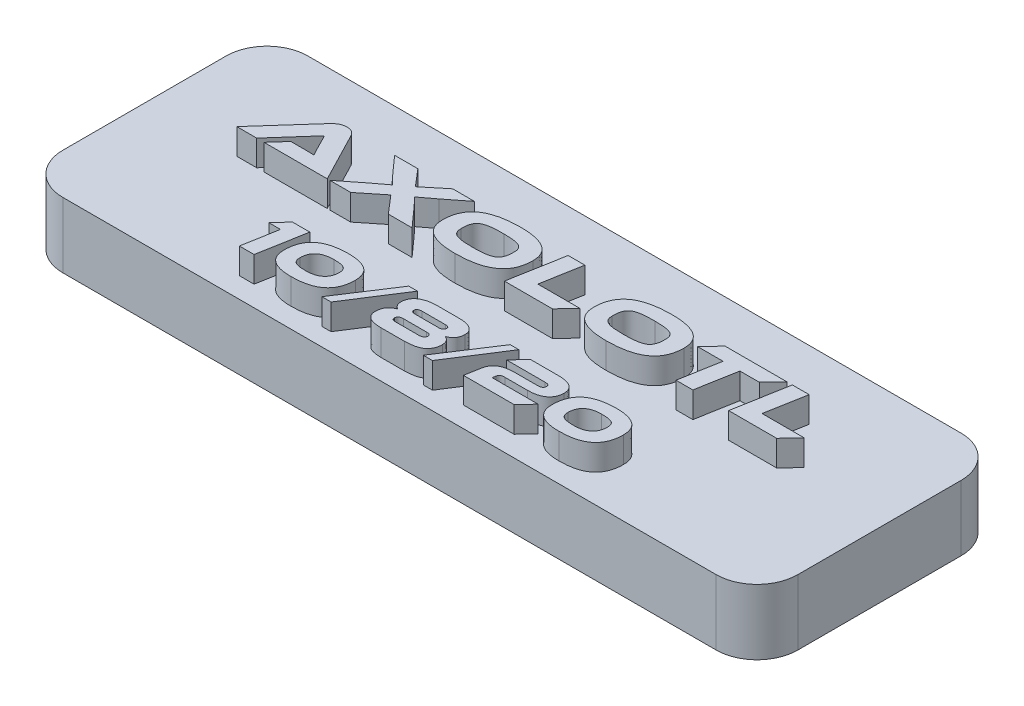
from build123d import *

# Parameters (mm, degrees)
SKETCH1_W           = 57.15
SKETCH1_H           = 19.05
BOSS_EXTRUDE1_DEPTH = 5.08
FILLET1_R           = 3.175
BOSS_EXTRUDE2_DEPTH = 2
SKETCH4_R           = 0.9
CUT_EXTRUDE1_DEPTH  = 4


with BuildPart() as part:
    # Sketch1 → Boss-Extrude1 (new body)
    with BuildSketch(Plane(origin=(0, 0, 0), x_dir=(1, 0, 0), z_dir=(0, 1, 0))):
        Rectangle(SKETCH1_W, SKETCH1_H)
    extrude(amount=BOSS_EXTRUDE1_DEPTH)

    # Fillet1
    fillet1_edges = [part.edges().sort_by_distance(p)[0] for p in [
        (-28.575, 2.54, -9.525),
        (-28.575, 2.54, 9.525),
        (28.575, 2.54, 9.525),
        (28.575, 2.54, -9.525),
    ]]
    fillet(fillet1_edges, radius=FILLET1_R)

    # Sketch3 → Boss-Extrude2 (add)
    with BuildSketch(Plane(origin=(0, 5.08, 0), x_dir=(1, 0, 0), z_dir=(0, 1, 0))):
        Polygon((18.335777087, 1.105536066), (18.8918259, 4.208766837), (17.59016618, 4.208766837), (16.838236535, 0.006075914), (20.572609811, 0.006075914), (21.615201335, 1.105536066), align=None)
        Polygon((12.363724781, 4.206347541), (11.314814521, 3.106887389), (13.298897784, 3.106887389), (12.749167708, 0.003655726), (14.057146165, 0.003655726), (14.613194977, 3.106887389), (16.117054266, 3.106887389), (17.165964526, 4.206347541), align=None)
        with BuildLine():
            add(Edge.make_bspline(
                [(8.150404133, 4.264853435), (8.077331419, 4.264150041), (7.933827308, 4.262768679), (7.722365677, 4.255304453), (7.518089939, 4.243828802), (7.320895791, 4.226275073), (7.130668478, 4.204448808), (6.947363902, 4.178135377), (6.771067152, 4.146346882), (6.601929756, 4.108703546), (6.439953656, 4.066841285), (6.285091092, 4.020018599), (6.136881333, 3.969271115), (5.995622238, 3.912462076), (5.861728018, 3.850145336), (5.733958554, 3.784672178), (5.61390929, 3.713307743), (5.501420481, 3.636054084), (5.394894648, 3.555015487), (5.296173928, 3.467997248), (5.204320413, 3.375795294), (5.118249102, 3.27972572), (5.040508005, 3.176938462), (4.967822763, 3.070861845), (4.904381991, 2.958180712), (4.844853282, 2.842029764), (4.794160472, 2.71956376), (4.750442622, 2.592115874), (4.712505364, 2.460138961), (4.682839934, 2.322911611), (4.658964556, 2.180763117), (4.641635021, 2.033740252), (4.631310583, 1.881481624), (4.630569657, 1.778351657), (4.630192995, 1.725923865)],
                knots=[0, 0, 0, 0, 0.00021922, 0.000430517, 0.000634719, 0.000832939, 0.001024345, 0.001209088, 0.001388397, 0.001561619, 0.0017288, 0.001890173, 0.002046865, 0.002198625, 0.002346687, 0.00248979, 0.002629165, 0.002765325, 0.002898982, 0.003030471, 0.003159752, 0.003289265, 0.003417071, 0.003546125, 0.003674706, 0.003804712, 0.003937476, 0.004071906, 0.004208776, 0.004349179, 0.004492852, 0.004641052, 0.004793135, 0.004950393, 0.004950393, 0.004950393, 0.004950393], degree=3))
            add(Edge.make_bspline(
                [(4.630192995, 1.725923865), (4.632121436, 1.652651179), (4.635862655, 1.510500548), (4.669901525, 1.304743113), (4.723090378, 1.113533359), (4.798787304, 0.936607339), (4.896339962, 0.774301847), (5.016174769, 0.627005612), (5.158132033, 0.495143384), (5.321021618, 0.377875494), (5.505459788, 0.275513814), (5.710884064, 0.187096535), (5.937068575, 0.111278664), (6.184896364, 0.05083109), (6.453342007, 0.003624777), (6.743027316, -0.029580863), (7.05393382, -0.049844784), (7.268410788, -0.051940053), (7.379055845, -0.053020966)],
                knots=[0, 0, 0, 0, 0.000219671, 0.000426167, 0.000623813, 0.000813827, 0.001001645, 0.001190103, 0.001381548, 0.00158123, 0.001790776, 0.002013083, 0.002251287, 0.002505594, 0.002777627, 0.003068474, 0.003379936, 0.003711836, 0.003711836, 0.003711836, 0.003711836], degree=3))
            add(Edge.make_bspline(
                [(7.379055845, -0.053020966), (7.451890511, -0.052455169), (7.595158518, -0.051342229), (7.806679132, -0.043724787), (8.010969019, -0.032438481), (8.208136511, -0.014624257), (8.398458377, 0.006825126), (8.581630129, 0.034388638), (8.757965362, 0.066140884), (8.926831283, 0.103671999), (9.089012016, 0.145843098), (9.244523494, 0.191939017), (9.392566548, 0.24436261), (9.533842253, 0.30061376), (9.667425433, 0.363320067), (9.79483723, 0.429548791), (9.914587653, 0.501958418), (10.027365803, 0.579052293), (10.133795921, 0.660209293), (10.232901001, 0.747143393), (10.324109817, 0.84029394), (10.410537302, 0.93631177), (10.488233002, 1.03914999), (10.560890265, 1.145233071), (10.624622924, 1.258074334), (10.683644253, 1.374784654), (10.7346216, 1.497412041), (10.778293943, 1.624884051), (10.816229151, 1.756856749), (10.846015196, 1.894369804), (10.86968361, 2.036857562), (10.887125791, 2.184166254), (10.897429012, 2.336428379), (10.898172865, 2.439557863), (10.898551014, 2.491985411)],
                knots=[0, 0, 0, 0, 0.0002185, 0.000429796, 0.000634912, 0.000832221, 0.001023627, 0.001209407, 0.001387817, 0.001561039, 0.001728219, 0.001890468, 0.002047461, 0.002199222, 0.002346454, 0.00248998, 0.002629824, 0.002765984, 0.002899642, 0.003031131, 0.00316106, 0.003290573, 0.003418378, 0.003547433, 0.003676014, 0.003806837, 0.003939601, 0.004074031, 0.004210901, 0.004351303, 0.004495879, 0.004644079, 0.004796161, 0.00495342, 0.00495342, 0.00495342, 0.00495342], degree=3))
            add(Edge.make_bspline(
                [(10.898551014, 2.491985411), (10.896470083, 2.564930001), (10.892417642, 2.706983534), (10.860286286, 2.912703512), (10.806289001, 3.104122883), (10.730299981, 3.280748696), (10.632346519, 3.44245971), (10.513207523, 3.589369287), (10.371798288, 3.721034434), (10.208286355, 3.837071522), (10.024253575, 3.940135668), (9.818210998, 4.0266221), (9.592344192, 4.102333874), (9.344326207, 4.161421518), (9.075707698, 4.208718585), (8.78575134, 4.242297194), (8.474770739, 4.261022072), (8.260326341, 4.263336881), (8.150404133, 4.264853435)],
                knots=[0, 0, 0, 0, 0.000218758, 0.000426013, 0.00062278, 0.000813995, 0.001001031, 0.001188203, 0.001379648, 0.001578795, 0.001788342, 0.002011126, 0.002248172, 0.002502261, 0.002775194, 0.003066041, 0.003377445, 0.003709345, 0.003709345, 0.003709345, 0.003709345], degree=3))
        make_face()
        with BuildLine():
            add(Edge.make_bspline(
                [(7.569080374, 1.047030173), (7.500559737, 1.04660261), (7.368640483, 1.045779446), (7.17778066, 1.049733712), (7.00161625, 1.061186797), (6.839512598, 1.075736974), (6.691844576, 1.097737934), (6.558517858, 1.125013299), (6.438678126, 1.156348623), (6.332812518, 1.194530349), (6.23896382, 1.240026498), (6.159068437, 1.297252332), (6.090462452, 1.363776891), (6.036559465, 1.441900597), (5.993689516, 1.529303822), (5.963864806, 1.627061382), (5.9462797, 1.735031597), (5.945271135, 1.81026116), (5.944747295, 1.849334734)],
                knots=[0, 0, 0, 0, 0.000205565, 0.000395764, 0.000572537, 0.000735087, 0.000883892, 0.001020147, 0.001143219, 0.001255139, 0.001357344, 0.001455005, 0.001548736, 0.001642574, 0.001738242, 0.001839729, 0.001948086, 0.002065187, 0.002065187, 0.002065187, 0.002065187], degree=3))
            add(Edge.make_bspline(
                [(5.944747295, 1.849334734), (5.943098774, 1.911811071), (5.939942925, 2.031412847), (5.951840709, 2.203375738), (5.976801723, 2.359667266), (6.015650402, 2.50079582), (6.068915694, 2.626166729), (6.134480308, 2.737052728), (6.216292456, 2.83042282), (6.295498537, 2.895436203), (6.366149285, 2.940784123), (6.426646367, 2.971515459), (6.493736891, 2.999666566), (6.567001749, 3.026084681), (6.646519384, 3.05083148), (6.732576181, 3.072755525), (6.825516283, 3.09131218), (6.924608683, 3.110411596), (7.030942267, 3.124111193), (7.143324465, 3.137374608), (7.262575478, 3.147018552), (7.388136832, 3.155167115), (7.520386226, 3.161792983), (7.659070377, 3.165320712), (7.804444012, 3.166041701), (7.903476417, 3.165221911), (7.954059082, 3.164803188)],
                knots=[0, 0, 0, 0, 0.000187411, 0.00035877, 0.00051627, 0.000661555, 0.000796714, 0.00092386, 0.001046319, 0.001167112, 0.001230003, 0.001297872, 0.001370374, 0.001448163, 0.001531436, 0.001620123, 0.001714428, 0.001815734, 0.00192278, 0.002035947, 0.002155212, 0.002281633, 0.002413427, 0.002552426, 0.00269778, 0.002849532, 0.002849532, 0.002849532, 0.002849532], degree=3))
            add(Edge.make_bspline(
                [(7.954059082, 3.164803188), (8.022924332, 3.165086646), (8.156102179, 3.165634822), (8.348524647, 3.161832074), (8.526217236, 3.150341942), (8.6895122, 3.135653139), (8.838161527, 3.114010286), (8.972295861, 3.086275793), (9.092329867, 3.055550786), (9.197949994, 3.01670025), (9.291498522, 2.971781209), (9.370742945, 2.913989507), (9.439068997, 2.847457656), (9.494266406, 2.770130915), (9.535912659, 2.682069422), (9.564669472, 2.584313015), (9.582527367, 2.476491904), (9.583494431, 2.401253582), (9.583996715, 2.362175459)],
                knots=[0, 0, 0, 0, 0.000206599, 0.00039954, 0.000577225, 0.000740685, 0.000891298, 0.001027553, 0.001151508, 0.001262569, 0.001364775, 0.001461693, 0.001555424, 0.00164979, 0.00174506, 0.001846279, 0.001954636, 0.002071737, 0.002071737, 0.002071737, 0.002071737], degree=3))
            add(Edge.make_bspline(
                [(9.583996715, 2.362175459), (9.585619089, 2.300007823), (9.588724223, 2.181022384), (9.577152523, 2.009565903), (9.550925729, 1.85401663), (9.511992566, 1.713235889), (9.459097938, 1.587793863), (9.392329774, 1.477427264), (9.310300781, 1.383606431), (9.230834209, 1.317707612), (9.159095801, 1.272767382), (9.098250778, 1.241979786), (9.031581199, 1.212524455), (8.957796539, 1.186264377), (8.877930547, 1.161664348), (8.79118721, 1.139884782), (8.698270511, 1.119635522), (8.598433299, 1.102726509), (8.492431364, 1.086938186), (8.379614117, 1.074209563), (8.260377611, 1.064550242), (8.13451608, 1.056272217), (8.002261892, 1.049750773), (7.863274865, 1.046182113), (7.717900831, 1.045470465), (7.618868482, 1.046288949), (7.569080374, 1.047030173)],
                knots=[0, 0, 0, 0, 0.000186496, 0.000356944, 0.000514595, 0.000659, 0.000794159, 0.000921781, 0.00104424, 0.00116632, 0.001229983, 0.001297853, 0.001370716, 0.001448505, 0.001532652, 0.001621339, 0.001716727, 0.001817873, 0.001925047, 0.002038214, 0.00215839, 0.002283899, 0.002416606, 0.002555606, 0.002700959, 0.002852711, 0.002852711, 0.002852711, 0.002852711], degree=3))
        make_face(mode=Mode.SUBTRACT)
        Polygon((0.901020759, 1.105536066), (1.457069572, 4.208766837), (0.155409851, 4.208766837), (-0.596519793, 0.006075914), (3.137853483, 0.006075914), (4.180445006, 1.105536066), align=None)
        with BuildLine():
            add(Edge.make_bspline(
                [(-3.609280505, 4.264853435), (-3.682353219, 4.264150041), (-3.825857329, 4.262768679), (-4.037318961, 4.255304453), (-4.241594699, 4.243828802), (-4.438788847, 4.226275073), (-4.62901616, 4.204448808), (-4.812320736, 4.178135377), (-4.988617486, 4.146346882), (-5.157754882, 4.108703546), (-5.319730982, 4.066841285), (-5.474593546, 4.020018599), (-5.622803305, 3.969271115), (-5.7640624, 3.912462076), (-5.897956619, 3.850145336), (-6.025726084, 3.784672178), (-6.145775348, 3.713307743), (-6.258264157, 3.636054084), (-6.36478999, 3.555015487), (-6.463510709, 3.467997248), (-6.555364225, 3.375795294), (-6.641435535, 3.27972572), (-6.719176633, 3.176938462), (-6.791861874, 3.070861845), (-6.855302646, 2.958180712), (-6.914831356, 2.842029764), (-6.965524166, 2.71956376), (-7.009242016, 2.592115874), (-7.047179274, 2.460138961), (-7.076844704, 2.322911611), (-7.100720082, 2.180763117), (-7.118049617, 2.033740252), (-7.128374055, 1.881481624), (-7.129114981, 1.778351657), (-7.129491643, 1.725923865)],
                knots=[0, 0, 0, 0, 0.00021922, 0.000430517, 0.000634719, 0.000832939, 0.001024345, 0.001209088, 0.001388397, 0.001561619, 0.0017288, 0.001890173, 0.002046865, 0.002198625, 0.002346687, 0.00248979, 0.002629165, 0.002765325, 0.002898982, 0.003030471, 0.003159752, 0.003289265, 0.003417071, 0.003546125, 0.003674706, 0.003804712, 0.003937476, 0.004071906, 0.004208776, 0.004349179, 0.004492852, 0.004641052, 0.004793135, 0.004950393, 0.004950393, 0.004950393, 0.004950393], degree=3))
            add(Edge.make_bspline(
                [(-7.129491643, 1.725923865), (-7.127563201, 1.652651179), (-7.123821983, 1.510500548), (-7.089783113, 1.304743113), (-7.036594259, 1.113533359), (-6.960897334, 0.936607339), (-6.863344676, 0.774301847), (-6.743509869, 0.627005612), (-6.601552605, 0.495143384), (-6.43866302, 0.377875494), (-6.25422485, 0.275513814), (-6.048800574, 0.187096535), (-5.822616063, 0.111278664), (-5.574788274, 0.05083109), (-5.306342631, 0.003624777), (-5.016657321, -0.029580863), (-4.705750818, -0.049844784), (-4.49127385, -0.051940053), (-4.380628792, -0.053020966)],
                knots=[0, 0, 0, 0, 0.000219671, 0.000426167, 0.000623813, 0.000813827, 0.001001645, 0.001190103, 0.001381548, 0.00158123, 0.001790776, 0.002013083, 0.002251287, 0.002505594, 0.002777627, 0.003068474, 0.003379936, 0.003711836, 0.003711836, 0.003711836, 0.003711836], degree=3))
            add(Edge.make_bspline(
                [(-4.380628792, -0.053020966), (-4.307794126, -0.052455169), (-4.16452612, -0.051342229), (-3.953005506, -0.043724787), (-3.748715619, -0.032438481), (-3.551548127, -0.014624257), (-3.361226261, 0.006825126), (-3.178054509, 0.034388638), (-3.001719275, 0.066140884), (-2.832853354, 0.103671999), (-2.670672622, 0.145843098), (-2.515161144, 0.191939017), (-2.367118089, 0.24436261), (-2.225842384, 0.30061376), (-2.092259205, 0.363320067), (-1.964847408, 0.429548791), (-1.845096985, 0.501958418), (-1.732318834, 0.579052293), (-1.625888717, 0.660209293), (-1.526783636, 0.747143393), (-1.435574821, 0.84029394), (-1.349147336, 0.93631177), (-1.271451635, 1.03914999), (-1.198794373, 1.145233071), (-1.135061714, 1.258074334), (-1.076040385, 1.374784654), (-1.025063038, 1.497412041), (-0.981390695, 1.624884051), (-0.943455487, 1.756856749), (-0.913669441, 1.894369804), (-0.890001028, 2.036857562), (-0.872558847, 2.184166254), (-0.862255625, 2.336428379), (-0.861511773, 2.439557863), (-0.861133623, 2.491985411)],
                knots=[0, 0, 0, 0, 0.0002185, 0.000429796, 0.000634912, 0.000832221, 0.001023627, 0.001209407, 0.001387817, 0.001561039, 0.001728219, 0.001890468, 0.002047461, 0.002199222, 0.002346454, 0.00248998, 0.002629824, 0.002765984, 0.002899642, 0.003031131, 0.00316106, 0.003290573, 0.003418378, 0.003547433, 0.003676014, 0.003806837, 0.003939601, 0.004074031, 0.004210901, 0.004351303, 0.004495879, 0.004644079, 0.004796161, 0.00495342, 0.00495342, 0.00495342, 0.00495342], degree=3))
            add(Edge.make_bspline(
                [(-0.861133623, 2.491985411), (-0.863214555, 2.564930001), (-0.867266996, 2.706983534), (-0.899398351, 2.912703512), (-0.953395637, 3.104122883), (-1.029384657, 3.280748696), (-1.127338119, 3.44245971), (-1.246477114, 3.589369287), (-1.387886349, 3.721034434), (-1.551398282, 3.837071522), (-1.735431063, 3.940135668), (-1.941473639, 4.0266221), (-2.167340445, 4.102333874), (-2.415358431, 4.161421518), (-2.683976939, 4.208718585), (-2.973933297, 4.242297194), (-3.284913899, 4.261022072), (-3.499358297, 4.263336881), (-3.609280505, 4.264853435)],
                knots=[0, 0, 0, 0, 0.000218758, 0.000426013, 0.00062278, 0.000813995, 0.001001031, 0.001188203, 0.001379648, 0.001578795, 0.001788342, 0.002011126, 0.002248172, 0.002502261, 0.002775194, 0.003066041, 0.003377445, 0.003709345, 0.003709345, 0.003709345, 0.003709345], degree=3))
        make_face()
        with BuildLine():
            add(Edge.make_bspline(
                [(-4.190604263, 1.047030173), (-4.259124901, 1.04660261), (-4.391044155, 1.045779446), (-4.581903978, 1.049733712), (-4.758068387, 1.061186797), (-4.920172039, 1.075736974), (-5.067840062, 1.097737934), (-5.20116678, 1.125013299), (-5.321006511, 1.156348623), (-5.42687212, 1.194530349), (-5.520720817, 1.240026498), (-5.600616201, 1.297252332), (-5.669222186, 1.363776891), (-5.723125172, 1.441900597), (-5.765995122, 1.529303822), (-5.795819832, 1.627061382), (-5.813404937, 1.735031597), (-5.814413503, 1.81026116), (-5.814937343, 1.849334734)],
                knots=[0, 0, 0, 0, 0.000205565, 0.000395764, 0.000572537, 0.000735087, 0.000883892, 0.001020147, 0.001143219, 0.001255139, 0.001357344, 0.001455005, 0.001548736, 0.001642574, 0.001738242, 0.001839729, 0.001948086, 0.002065187, 0.002065187, 0.002065187, 0.002065187], degree=3))
            add(Edge.make_bspline(
                [(-5.814937343, 1.849334734), (-5.816585863, 1.911811071), (-5.819741713, 2.031412847), (-5.807843928, 2.203375738), (-5.782882914, 2.359667266), (-5.744034235, 2.50079582), (-5.690768944, 2.626166729), (-5.62520433, 2.737052728), (-5.543392182, 2.83042282), (-5.464186101, 2.895436203), (-5.393535353, 2.940784123), (-5.33303827, 2.971515459), (-5.265947746, 2.999666566), (-5.192682889, 3.026084681), (-5.113165253, 3.05083148), (-5.027108456, 3.072755525), (-4.934168354, 3.09131218), (-4.835075955, 3.110411596), (-4.72874237, 3.124111193), (-4.616360173, 3.137374608), (-4.49710916, 3.147018552), (-4.371547805, 3.155167115), (-4.239298411, 3.161792983), (-4.100614261, 3.165320712), (-3.955240626, 3.166041701), (-3.856208221, 3.165221911), (-3.805625556, 3.164803188)],
                knots=[0, 0, 0, 0, 0.000187411, 0.00035877, 0.00051627, 0.000661555, 0.000796714, 0.00092386, 0.001046319, 0.001167112, 0.001230003, 0.001297872, 0.001370374, 0.001448163, 0.001531436, 0.001620123, 0.001714428, 0.001815734, 0.00192278, 0.002035947, 0.002155212, 0.002281633, 0.002413427, 0.002552426, 0.00269778, 0.002849532, 0.002849532, 0.002849532, 0.002849532], degree=3))
            add(Edge.make_bspline(
                [(-3.805625556, 3.164803188), (-3.736760306, 3.165086646), (-3.603582459, 3.165634822), (-3.411159991, 3.161832074), (-3.233467401, 3.150341942), (-3.070172438, 3.135653139), (-2.921523111, 3.114010286), (-2.787388776, 3.086275793), (-2.667354771, 3.055550786), (-2.561734644, 3.01670025), (-2.468186116, 2.971781209), (-2.388941693, 2.913989507), (-2.32061564, 2.847457656), (-2.265418231, 2.770130915), (-2.223771978, 2.682069422), (-2.195015166, 2.584313015), (-2.17715727, 2.476491904), (-2.176190207, 2.401253582), (-2.175687923, 2.362175459)],
                knots=[0, 0, 0, 0, 0.000206599, 0.00039954, 0.000577225, 0.000740685, 0.000891298, 0.001027553, 0.001151508, 0.001262569, 0.001364775, 0.001461693, 0.001555424, 0.00164979, 0.00174506, 0.001846279, 0.001954636, 0.002071737, 0.002071737, 0.002071737, 0.002071737], degree=3))
            add(Edge.make_bspline(
                [(-2.175687923, 2.362175459), (-2.174065549, 2.300007823), (-2.170960415, 2.181022384), (-2.182532115, 2.009565903), (-2.208758908, 1.85401663), (-2.247692072, 1.713235889), (-2.300586699, 1.587793863), (-2.367354863, 1.477427264), (-2.449383856, 1.383606431), (-2.528850429, 1.317707612), (-2.600588836, 1.272767382), (-2.66143386, 1.241979786), (-2.728103439, 1.212524455), (-2.801888099, 1.186264377), (-2.881754091, 1.161664348), (-2.968497428, 1.139884782), (-3.061414126, 1.119635522), (-3.161251339, 1.102726509), (-3.267253273, 1.086938186), (-3.380070521, 1.074209563), (-3.499307027, 1.064550242), (-3.625168558, 1.056272217), (-3.757422745, 1.049750773), (-3.896409773, 1.046182113), (-4.041783806, 1.045470465), (-4.140816156, 1.046288949), (-4.190604263, 1.047030173)],
                knots=[0, 0, 0, 0, 0.000186496, 0.000356944, 0.000514595, 0.000659, 0.000794159, 0.000921781, 0.00104424, 0.00116632, 0.001229983, 0.001297853, 0.001370716, 0.001448505, 0.001532652, 0.001621339, 0.001716727, 0.001817873, 0.001925047, 0.002038214, 0.00215839, 0.002283899, 0.002416606, 0.002555606, 0.002700959, 0.002852711, 0.002852711, 0.002852711, 0.002852711], degree=3))
        make_face(mode=Mode.SUBTRACT)
        with BuildLine():
            Line((-8.822368462, 4.208766837), (-10.414690062, 2.901365975))
            Line((-10.414690062, 2.901365975), (-11.526787687, 4.208766837))
            Line((-11.526787687, 4.208766837), (-13.333946328, 4.208766837))
            Line((-13.333946328, 4.208766837), (-12.259761122, 3.001937264))
            add(Edge.make_bspline(
                [(-12.259761122, 3.001937264), (-12.227529075, 2.96565322), (-12.165783675, 2.896145602), (-12.075414469, 2.796969781), (-11.992779685, 2.706215813), (-11.917581363, 2.623295629), (-11.84937037, 2.549789979), (-11.788383496, 2.484598936), (-11.736028023, 2.426996634), (-11.676580686, 2.36453497), (-11.613161538, 2.296940303), (-11.543692114, 2.228942305), (-11.485280404, 2.173290536), (-11.448682587, 2.142040461), (-11.432417295, 2.128151884)],
                knots=[0, 0, 0, 0, 0.000145597, 0.000278913, 0.000402513, 0.000513815, 0.000614729, 0.000703345, 0.000781627, 0.000848235, 0.000962032, 0.001059641, 0.001139837, 0.001203991, 0.001203991, 0.001203991, 0.001203991], degree=3))
            add(Edge.make_bspline(
                [(-11.432417295, 2.128151884), (-11.454399409, 2.113282778), (-11.503551915, 2.08003512), (-11.584507677, 2.02300337), (-11.679698933, 1.952538971), (-11.770110025, 1.885783864), (-11.85248483, 1.822945094), (-11.926749425, 1.767565893), (-12.009951958, 1.703189998), (-12.102932692, 1.630937748), (-12.206451011, 1.551777369), (-12.318890397, 1.463622082), (-12.441078055, 1.36793568), (-12.525753327, 1.30146059), (-12.569625604, 1.267018261)],
                knots=[0, 0, 0, 0, 7.9615e-05, 0.000178022, 0.000297052, 0.000434907, 0.000515171, 0.000607866, 0.000712819, 0.000830759, 0.000961128, 0.001103763, 0.001259387, 0.001426717, 0.001426717, 0.001426717, 0.001426717], degree=3))
            Line((-12.569625604, 1.267018261), (-14.168019547, 0.003655726))
            Line((-14.168019547, 0.003655726), (-12.544104265, 0.003655726))
            Line((-12.544104265, 0.003655726), (-10.812770462, 1.392796648))
            Line((-10.812770462, 1.392796648), (-9.618529262, 0.003655726))
            Line((-9.618529262, 0.003655726), (-7.773458202, 0.003655726))
            Line((-7.773458202, 0.003655726), (-8.904512036, 1.267082537))
            add(Edge.make_bspline(
                [(-8.904512036, 1.267082537), (-8.953109035, 1.320639375), (-9.046940223, 1.424047029), (-9.182302296, 1.575101317), (-9.31044675, 1.71398902), (-9.426715977, 1.842642286), (-9.530124306, 1.955855654), (-9.619642753, 2.049203927), (-9.692994479, 2.12197018), (-9.738330801, 2.16153788), (-9.757686087, 2.178430386)],
                knots=[0, 0, 0, 0, 0.000216956, 0.0004189, 0.000608483, 0.00078386, 0.000939132, 0.001068438, 0.001171871, 0.001248926, 0.001248926, 0.001248926, 0.001248926], degree=3))
            add(Edge.make_bspline(
                [(-9.757686087, 2.178430386), (-9.736012002, 2.193611207), (-9.687528242, 2.227569887), (-9.607724768, 2.285528044), (-9.51351167, 2.355646824), (-9.424468197, 2.421589531), (-9.344741477, 2.483177947), (-9.273688332, 2.536333869), (-9.194348821, 2.596129235), (-9.107949442, 2.664537016), (-9.011639276, 2.737157725), (-8.907257325, 2.816774485), (-8.795100235, 2.903684473), (-8.717386907, 2.96370059), (-8.677155362, 2.994770435)],
                knots=[0, 0, 0, 0, 7.9384e-05, 0.000177578, 0.000295872, 0.000431716, 0.000509971, 0.000598095, 0.000697922, 0.000808005, 0.000928677, 0.001059771, 0.001201845, 0.001354342, 0.001354342, 0.001354342, 0.001354342], degree=3))
            Line((-8.677155362, 2.994770435), (-7.128947078, 4.208766837))
            Line((-7.128947078, 4.208766837), (-8.822368462, 4.208766837))
        make_face()
        with BuildLine():
            Line((-14.369403161, 0.006075914), (-16.334530215, 3.800574494))
            add(Edge.make_bspline(
                [(-16.334530215, 3.800574494), (-16.352651159, 3.832806008), (-16.388609822, 3.896765269), (-16.453483512, 3.985575321), (-16.530742999, 4.0630874), (-16.61564591, 4.133983071), (-16.713451804, 4.192399523), (-16.825562954, 4.23493807), (-16.951604781, 4.260058315), (-17.040335714, 4.264204191), (-17.08646343, 4.266359469)],
                knots=[0, 0, 0, 0, 0.000110886, 0.000220038, 0.000328642, 0.000438436, 0.000551159, 0.000668641, 0.000796469, 0.000934872, 0.000934872, 0.000934872, 0.000934872], degree=3))
            add(Edge.make_bspline(
                [(-17.08646343, 4.266359469), (-17.13627509, 4.264009128), (-17.23300621, 4.259444915), (-17.373044966, 4.230967468), (-17.503323528, 4.187726952), (-17.623058403, 4.126959855), (-17.732740059, 4.055096369), (-17.835941413, 3.977511138), (-17.930247626, 3.892229282), (-17.987630129, 3.830720556), (-18.016158647, 3.800140628)],
                knots=[0, 0, 0, 0, 0.00014941, 0.000290146, 0.000427171, 0.000560039, 0.000691642, 0.000820174, 0.000947034, 0.001072464, 0.001072464, 0.001072464, 0.001072464], degree=3))
            Line((-18.016158647, 3.800140628), (-21.402156894, 0.006075914))
            Line((-21.402156894, 0.006075914), (-19.854066449, 0.006075914))
            Line((-19.854066449, 0.006075914), (-17.377121738, 2.798493231))
            Line((-17.377121738, 2.798493231), (-16.814754189, 1.696826253))
            add(Edge.make_bspline(
                [(-16.814754189, 1.696826253), (-16.788080184, 1.644325557), (-16.733563938, 1.5370248), (-16.664135596, 1.403208105), (-16.608052502, 1.297464771), (-16.566911388, 1.223921613), (-16.530507546, 1.155498073), (-16.505209241, 1.112747401), (-16.493177101, 1.092414734)],
                knots=[0, 0, 0, 0, 0.000176664, 0.000361065, 0.000452265, 0.000535729, 0.000613867, 0.000684736, 0.000684736, 0.000684736, 0.000684736], degree=3))
            add(Edge.make_bspline(
                [(-16.493177101, 1.092414734), (-16.548625446, 1.095166522), (-16.666785281, 1.101030553), (-16.851215817, 1.103502684), (-17.046234683, 1.10564963), (-17.17848728, 1.105358474), (-17.244612174, 1.105212899)],
                knots=[0, 0, 0, 0, 0.000166537, 0.000354888, 0.000553268, 0.00075164, 0.00075164, 0.00075164, 0.00075164], degree=3))
            Line((-17.244612174, 1.105212899), (-18.299657268, 1.105536066))
            Line((-18.299657268, 1.105536066), (-19.285380164, 0.006075914))
            Line((-19.285380164, 0.006075914), (-14.369403161, 0.006075914))
        make_face()
        with BuildLine():
            add(Edge.make_bspline(
                [(12.323148012, -4.205753245), (12.266046656, -4.20639815), (12.153714585, -4.207666832), (11.988003159, -4.213805403), (11.827992372, -4.225246011), (11.673478768, -4.240095428), (11.524583991, -4.260037206), (11.381366646, -4.284920981), (11.243455066, -4.313802188), (11.110906039, -4.346120038), (10.98409213, -4.383749272), (10.863154903, -4.426552533), (10.747132272, -4.472224962), (10.637277998, -4.524117338), (10.532209305, -4.578873484), (10.43319301, -4.638857599), (10.339718375, -4.703243715), (10.251904365, -4.771965987), (10.169046132, -4.844826576), (10.092052491, -4.922821718), (10.020487527, -5.005043307), (9.953077895, -5.090962924), (9.892969135, -5.18251662), (9.836377264, -5.277290921), (9.787211195, -5.377585075), (9.741083224, -5.480915677), (9.702209598, -5.589719203), (9.667828881, -5.702636581), (9.638017879, -5.819692193), (9.615162927, -5.941608197), (9.596563787, -6.06752364), (9.58425494, -6.198094357), (9.575704292, -6.332815699), (9.574989836, -6.424102975), (9.57462663, -6.470510423)],
                knots=[0, 0, 0, 0, 0.000171312, 0.000337012, 0.00049738, 0.000652505, 0.000802621, 0.000947932, 0.001088493, 0.001225264, 0.001357119, 0.001485126, 0.001610044, 0.001730996, 0.001849428, 0.001965345, 0.002078058, 0.002189744, 0.002299681, 0.002408844, 0.002518253, 0.002626572, 0.002736165, 0.002846598, 0.002957491, 0.003071033, 0.00318591, 0.003303822, 0.003425073, 0.003548063, 0.003675777, 0.003806785, 0.003941403, 0.004080604, 0.004080604, 0.004080604, 0.004080604], degree=3))
            add(Edge.make_bspline(
                [(9.57462663, -6.470510423), (9.575984284, -6.532725476), (9.578618024, -6.653417738), (9.604005146, -6.827938058), (9.644528364, -6.990047106), (9.701322743, -7.14024227), (9.775268453, -7.277956037), (9.865829045, -7.403136721), (9.972159356, -7.515956622), (10.095216909, -7.616000774), (10.234703204, -7.702745849), (10.389323028, -7.779438213), (10.560435671, -7.842507446), (10.746994226, -7.895609169), (10.949809636, -7.935791135), (11.168390515, -7.964127031), (11.402899395, -7.98091947), (11.564446134, -7.982880129), (11.647929239, -7.983893345)],
                knots=[0, 0, 0, 0, 0.000186545, 0.000361882, 0.000527754, 0.000687003, 0.000842323, 0.000995285, 0.001149196, 0.001306104, 0.001469661, 0.00164101, 0.001823006, 0.002015943, 0.002222385, 0.002442644, 0.002676813, 0.00292724, 0.00292724, 0.00292724, 0.00292724], degree=3))
            add(Edge.make_bspline(
                [(11.647929239, -7.983893345), (11.704726803, -7.983380019), (11.816224872, -7.98237232), (11.980815705, -7.975990544), (12.13983036, -7.965003258), (12.293685743, -7.948680913), (12.442137684, -7.929266178), (12.58477665, -7.904105738), (12.7220434, -7.875596387), (12.853545014, -7.841995411), (12.979894267, -7.804464931), (13.100431249, -7.761989808), (13.215969527, -7.715814846), (13.325764863, -7.664606669), (13.429742873, -7.608490903), (13.528661511, -7.548339608), (13.622034327, -7.483895632), (13.709743655, -7.414499954), (13.792148504, -7.341424669), (13.868149395, -7.262809113), (13.940738078, -7.18190029), (14.006267234, -7.094705032), (14.066945585, -7.003516426), (14.123356651, -6.908219643), (14.173518852, -6.808134503), (14.218456575, -6.703993625), (14.257548037, -6.595424725), (14.292218322, -6.482622195), (14.320540338, -6.364960314), (14.344776446, -6.243348255), (14.363182399, -6.117331748), (14.375557412, -5.986773695), (14.384033333, -5.851777937), (14.384765494, -5.760225753), (14.385136618, -5.713818961)],
                knots=[0, 0, 0, 0, 0.000170392, 0.000334494, 0.000494064, 0.000648473, 0.00079859, 0.000943113, 0.001082891, 0.001219081, 0.001350169, 0.001478176, 0.001602352, 0.001723304, 0.001841405, 0.001956639, 0.002070464, 0.002181522, 0.00229199, 0.002400592, 0.0025094, 0.002617866, 0.002727459, 0.002837893, 0.002949859, 0.003063082, 0.00317796, 0.003295871, 0.003416929, 0.003540857, 0.00366778, 0.003798788, 0.003934205, 0.004073405, 0.004073405, 0.004073405, 0.004073405], degree=3))
            add(Edge.make_bspline(
                [(14.385136618, -5.713818961), (14.383794963, -5.651864372), (14.381186832, -5.53142685), (14.355474268, -5.357329546), (14.316286782, -5.194951682), (14.259261315, -5.045253766), (14.185893198, -4.907894424), (14.096638097, -4.782830639), (13.990533291, -4.670804764), (13.868912487, -4.570938519), (13.730364377, -4.484275151), (13.576174682, -4.409545186), (13.406296477, -4.345204255), (13.220369076, -4.293863202), (13.018437906, -4.25419887), (12.800976271, -4.225768444), (12.56726263, -4.209016704), (12.406248759, -4.207051109), (12.323148012, -4.205753245)],
                knots=[0, 0, 0, 0, 0.000185746, 0.000361083, 0.00052676, 0.000686009, 0.000840246, 0.000992741, 0.001145521, 0.00130181, 0.001463587, 0.001634583, 0.001815083, 0.002007802, 0.002212518, 0.002431984, 0.002665356, 0.002914983, 0.002914983, 0.002914983, 0.002914983], degree=3))
        make_face()
        with BuildLine():
            add(Edge.make_bspline(
                [(11.814489723, -7.021348599), (11.768296643, -7.021854174), (11.679142108, -7.022829956), (11.550227113, -7.017591194), (11.43088165, -7.009340097), (11.321120551, -6.995853431), (11.220856509, -6.977791428), (11.130313176, -6.954558851), (11.048973951, -6.92776808), (10.976766135, -6.89577873), (10.912774773, -6.85746675), (10.858748202, -6.809228041), (10.81217849, -6.753532905), (10.775628179, -6.688452997), (10.746493114, -6.615916979), (10.72703231, -6.534816355), (10.714720155, -6.445830998), (10.714024561, -6.383634321), (10.713663249, -6.351327518)],
                knots=[0, 0, 0, 0, 0.000138565, 0.000267436, 0.000386943, 0.000497368, 0.000599032, 0.000692348, 0.000777591, 0.00085564, 0.000928899, 0.001000308, 0.001071897, 0.001145712, 0.001223247, 0.001305698, 0.001395292, 0.001492131, 0.001492131, 0.001492131, 0.001492131], degree=3))
            add(Edge.make_bspline(
                [(10.713663249, -6.351327518), (10.715200102, -6.304070169), (10.718190189, -6.212126705), (10.736852129, -6.079013736), (10.766107572, -5.954439253), (10.807925391, -5.839274516), (10.859983019, -5.731825667), (10.925193241, -5.634468641), (11.001009111, -5.545120744), (11.088954658, -5.466071948), (11.186927734, -5.395226287), (11.295530212, -5.334487382), (11.413910748, -5.283435533), (11.541504354, -5.240941797), (11.678837325, -5.208296683), (11.825707186, -5.185693562), (11.982241404, -5.170762309), (12.089962721, -5.169135367), (12.145457874, -5.16829721)],
                knots=[0, 0, 0, 0, 0.000141763, 0.000275812, 0.0004025, 0.000524963, 0.000642655, 0.000759791, 0.000875529, 0.00099331, 0.001113634, 0.001237554, 0.001365798, 0.001499859, 0.001640517, 0.001788722, 0.001945363, 0.002111808, 0.002111808, 0.002111808, 0.002111808], degree=3))
            add(Edge.make_bspline(
                [(12.145457874, -5.16829721), (12.191586523, -5.168009724), (12.280664843, -5.167454564), (12.409815156, -5.171313587), (12.529426288, -5.17974049), (12.639363374, -5.193477036), (12.739656582, -5.210588071), (12.830368338, -5.232796313), (12.91156264, -5.25982086), (12.983847428, -5.291687778), (13.047473021, -5.330152418), (13.101868387, -5.377160874), (13.147455683, -5.432670471), (13.184380226, -5.496790682), (13.213229541, -5.569240936), (13.232656566, -5.650050065), (13.245092093, -5.738759012), (13.245754472, -5.80069376), (13.2461, -5.833001866)],
                knots=[0, 0, 0, 0, 0.00013838, 0.000267224, 0.000387529, 0.000497953, 0.000599476, 0.000692596, 0.00077784, 0.000855889, 0.000929147, 0.001000031, 0.001070493, 0.001143616, 0.001221151, 0.001303602, 0.001392403, 0.001489242, 0.001489242, 0.001489242, 0.001489242], degree=3))
            add(Edge.make_bspline(
                [(13.2461, -5.833001866), (13.24456248, -5.880258006), (13.241571096, -5.972199119), (13.222882261, -6.105585977), (13.193521312, -6.230260661), (13.152818647, -6.346409008), (13.09981649, -6.453739693), (13.034399228, -6.551573704), (12.958755218, -6.64153852), (12.871113218, -6.721564153), (12.772698271, -6.791879743), (12.665153386, -6.854243117), (12.546604048, -6.904835069), (12.418963915, -6.947243215), (12.281768742, -6.980841995), (12.134667178, -7.004512108), (11.977776429, -7.019068958), (11.869796799, -7.020761541), (11.814489723, -7.021348599)],
                knots=[0, 0, 0, 0, 0.000141763, 0.000275812, 0.000403278, 0.000525472, 0.000644235, 0.000761371, 0.000877718, 0.000996039, 0.001116363, 0.001239983, 0.001368227, 0.001502288, 0.001643134, 0.001791467, 0.001948904, 0.002115349, 0.002115349, 0.002115349, 0.002115349], degree=3))
        make_face(mode=Mode.SUBTRACT)
        with BuildLine():
            Line((4.791851727, -5.218973535), (7.782983621, -5.218973535))
            add(Edge.make_bspline(
                [(7.782983621, -5.218973535), (7.810684535, -5.218922741), (7.86253091, -5.218827674), (7.935259913, -5.225918073), (7.996783954, -5.242216387), (8.048614491, -5.26353583), (8.08870788, -5.294908436), (8.11702188, -5.334273792), (8.134573857, -5.381008794), (8.135798557, -5.4147712), (8.136432923, -5.432259348)],
                knots=[0, 0, 0, 0, 8.3099e-05, 0.000155531, 0.000218392, 0.000273538, 0.000322508, 0.000368908, 0.000417497, 0.000469711, 0.000469711, 0.000469711, 0.000469711], degree=3))
            add(Edge.make_bspline(
                [(8.136432923, -5.432259348), (8.135793129, -5.458018948), (8.134583525, -5.506720508), (8.114021139, -5.573936821), (8.080734763, -5.630194031), (8.03152114, -5.673414306), (7.967990041, -5.704561408), (7.890255874, -5.726311626), (7.797130715, -5.738498194), (7.73012907, -5.73961472), (7.694096371, -5.740215175)],
                knots=[0, 0, 0, 0, 7.6993e-05, 0.000145564, 0.000208395, 0.000270703, 0.000339032, 0.00041902, 0.000511893, 0.000619952, 0.000619952, 0.000619952, 0.000619952], degree=3))
            Line((7.694096371, -5.740215175), (5.936332877, -5.739416071))
            add(Edge.make_bspline(
                [(5.936332877, -5.739416071), (5.880730721, -5.740560639), (5.772477559, -5.742789025), (5.614482232, -5.753609346), (5.465762873, -5.772857955), (5.326140005, -5.798779792), (5.195876807, -5.833149331), (5.074797954, -5.875619954), (4.962530574, -5.92500466), (4.859328707, -5.98174212), (4.76585951, -6.047028209), (4.681334017, -6.120143527), (4.605933408, -6.201107035), (4.539932386, -6.289606037), (4.483550812, -6.385733808), (4.436455057, -6.489539314), (4.397507694, -6.600822081), (4.380186018, -6.678800473), (4.371372977, -6.718474855)],
                knots=[0, 0, 0, 0, 0.000166829, 0.000324804, 0.000474816, 0.000616477, 0.000750546, 0.000878553, 0.001001026, 0.001118108, 0.001231277, 0.001342418, 0.001452782, 0.001562526, 0.00167296, 0.001786425, 0.001904052, 0.002025887, 0.002025887, 0.002025887, 0.002025887], degree=3))
            Line((4.371372977, -6.718474855), (4.156028866, -7.932183575))
            Line((4.156028866, -7.932183575), (8.09260171, -7.932183575))
            Line((8.09260171, -7.932183575), (8.999340399, -6.970155942))
            Line((8.999340399, -6.970155942), (5.427674588, -6.970155942))
            Line((5.427674588, -6.970155942), (5.477434638, -6.707239748))
            add(Edge.make_bspline(
                [(5.477434638, -6.707239748), (5.481212162, -6.686112106), (5.488534919, -6.645156023), (5.517246272, -6.590591717), (5.555606965, -6.543848716), (5.606946296, -6.508043577), (5.668021763, -6.47963759), (5.740339383, -6.461031101), (5.823402804, -6.450993538), (5.882326314, -6.450679637), (5.913551769, -6.450513291)],
                knots=[0, 0, 0, 0, 6.4036e-05, 0.000124134, 0.000182613, 0.000243892, 0.000310094, 0.000383827, 0.000466868, 0.000560486, 0.000560486, 0.000560486, 0.000560486], degree=3))
            Line((5.913551769, -6.450513291), (7.672405732, -6.449714187))
            add(Edge.make_bspline(
                [(7.672405732, -6.449714187), (7.738086757, -6.448593152), (7.865421198, -6.446419826), (8.049319047, -6.426694059), (8.220735657, -6.400940141), (8.378582543, -6.361961645), (8.524336537, -6.315052912), (8.655677792, -6.255202462), (8.775150907, -6.187512089), (8.879863347, -6.107690588), (8.972446539, -6.020066732), (9.0529029, -5.925525662), (9.120681785, -5.823724541), (9.176434587, -5.715194429), (9.218570556, -5.599220599), (9.249265992, -5.476792913), (9.266921337, -5.347458364), (9.268874291, -5.259004345), (9.269870344, -5.21389067)],
                knots=[0, 0, 0, 0, 0.00019697, 0.000381861, 0.000554393, 0.000716581, 0.000869107, 0.001013024, 0.00114885, 0.001280192, 0.001406932, 0.001530654, 0.001651783, 0.001773055, 0.001895792, 0.002021116, 0.002151095, 0.002286391, 0.002286391, 0.002286391, 0.002286391], degree=3))
            add(Edge.make_bspline(
                [(9.269870344, -5.21389067), (9.269417889, -5.1780961), (9.268532145, -5.108023129), (9.252322297, -5.005989197), (9.228330225, -4.909275966), (9.191795522, -4.818686266), (9.144161169, -4.734234215), (9.086082127, -4.655338408), (9.0177145, -4.582231577), (8.93842006, -4.515185386), (8.847597143, -4.455053695), (8.744018523, -4.402688892), (8.627785402, -4.359688685), (8.499597923, -4.322394884), (8.358794914, -4.294289614), (8.205447868, -4.27367202), (8.039581338, -4.26108405), (7.924751722, -4.258543735), (7.865271818, -4.257227893)],
                knots=[0, 0, 0, 0, 0.000107259, 0.000209975, 0.000309113, 0.00040566, 0.000501999, 0.00059927, 0.000698874, 0.0008016, 0.000910084, 0.001024914, 0.001148961, 0.001281358, 0.001425053, 0.00157924, 0.00174531, 0.001923772, 0.001923772, 0.001923772, 0.001923772], degree=3))
            Line((7.865271818, -4.257227893), (5.698590416, -4.256945902))
            Line((5.698590416, -4.256945902), (4.791851727, -5.218973535))
        make_face()
        Polygon((3.906041286, -4.05005839), (1.241114164, -8.139071868), (1.954341547, -8.139071868), (4.580566408, -4.05005839), align=None)
        with BuildLine():
            add(Edge.make_bspline(
                [(-0.440119682, -7.932183575), (-0.398458125, -7.931231171), (-0.316488475, -7.929357303), (-0.195847277, -7.92303202), (-0.080390866, -7.913299393), (0.029849534, -7.901630571), (0.134605641, -7.886120178), (0.234527684, -7.869023985), (0.328904968, -7.848038176), (0.417779194, -7.824924016), (0.501491555, -7.79951071), (0.579796069, -7.770456276), (0.653592658, -7.739757788), (0.721541229, -7.705166947), (0.784537892, -7.668342595), (0.841963815, -7.628415757), (0.894315097, -7.586096005), (0.955599102, -7.52618861), (1.02366429, -7.44788067), (1.09439859, -7.349322028), (1.153320863, -7.24731168), (1.199835497, -7.14179993), (1.235505456, -7.033385143), (1.258721792, -6.921252912), (1.270171396, -6.805633592), (1.268608474, -6.727559312), (1.267818146, -6.688079215)],
                knots=[0, 0, 0, 0, 0.000125013, 0.000245965, 0.000362345, 0.000472585, 0.000578466, 0.000679988, 0.000776639, 0.000868406, 0.000955443, 0.001038954, 0.001118882, 0.001195077, 0.00126751, 0.001337627, 0.001404712, 0.001469201, 0.001594487, 0.00171546, 0.001832632, 0.001947228, 0.002060803, 0.002174381, 0.002290108, 0.002408491, 0.002408491, 0.002408491, 0.002408491], degree=3))
            add(Edge.make_bspline(
                [(1.267818146, -6.688079215), (1.265849248, -6.645013118), (1.262060135, -6.562133096), (1.236841692, -6.444672392), (1.198182377, -6.339091581), (1.142090633, -6.248261694), (1.074407891, -6.170723555), (0.99668462, -6.10705473), (0.91013945, -6.055649416), (0.846506967, -6.034755311), (0.8142832, -6.024174444)],
                knots=[0, 0, 0, 0, 0.000129139, 0.000248525, 0.000358904, 0.000464809, 0.000566844, 0.000666291, 0.000765209, 0.000866693, 0.000866693, 0.000866693, 0.000866693], degree=3))
            add(Edge.make_bspline(
                [(0.8142832, -6.024174444), (0.855613856, -6.009960653), (0.938898007, -5.981318874), (1.055358171, -5.914739414), (1.165085179, -5.831227741), (1.249909867, -5.748532962), (1.311300938, -5.672798575), (1.352628003, -5.610121102), (1.386715735, -5.541280496), (1.41636167, -5.468161351), (1.439873474, -5.389726388), (1.45592631, -5.306040388), (1.468637164, -5.217443624), (1.471251798, -5.156345524), (1.472588774, -5.125103406)],
                knots=[0, 0, 0, 0, 0.000130881, 0.000263734, 0.000400196, 0.000543864, 0.000617818, 0.000692362, 0.000768557, 0.000847875, 0.000928857, 0.001013724, 0.001103318, 0.001197072, 0.001197072, 0.001197072, 0.001197072], degree=3))
            add(Edge.make_bspline(
                [(1.472588774, -5.125103406), (1.471368439, -5.090349443), (1.468995811, -5.022779311), (1.450296138, -4.92500398), (1.423784077, -4.833420282), (1.38581115, -4.748206931), (1.336441354, -4.670138756), (1.276973213, -4.59864822), (1.206924431, -4.533829851), (1.127053898, -4.475835581), (1.037529486, -4.424616933), (0.939673333, -4.38005075), (0.833833613, -4.341545727), (0.719584017, -4.310438157), (0.597112921, -4.286642109), (0.46641669, -4.270305953), (0.327858506, -4.259700382), (0.232786758, -4.258066688), (0.183973611, -4.257227893)],
                knots=[0, 0, 0, 0, 0.000104182, 0.000202555, 0.000297711, 0.000389729, 0.000481385, 0.000573968, 0.000667919, 0.000766953, 0.000869442, 0.000976817, 0.001089166, 0.001206956, 0.001331669, 0.001463128, 0.001601898, 0.001748332, 0.001748332, 0.001748332, 0.001748332], degree=3))
            Line((0.183973611, -4.257227893), (-1.568014149, -4.256945902))
            add(Edge.make_bspline(
                [(-1.568014149, -4.256945902), (-1.629288163, -4.257933345), (-1.748624688, -4.259856478), (-1.922985201, -4.27445031), (-2.087550847, -4.298184588), (-2.242569627, -4.330928531), (-2.387966279, -4.372216855), (-2.523742898, -4.423370326), (-2.649727247, -4.48435463), (-2.765940439, -4.553771073), (-2.871340405, -4.631408275), (-2.962188667, -4.719750309), (-3.041047113, -4.815062538), (-3.104419699, -4.920560106), (-3.155185208, -5.033834732), (-3.191927827, -5.155860959), (-3.215538677, -5.286067538), (-3.219771952, -5.375899516), (-3.22193785, -5.421860839)],
                knots=[0, 0, 0, 0, 0.000183805, 0.000357976, 0.000524491, 0.000682313, 0.000832949, 0.000977498, 0.00111702, 0.001252279, 0.00138314, 0.001508725, 0.001631528, 0.001753207, 0.001876737, 0.002003, 0.002134641, 0.002272556, 0.002272556, 0.002272556, 0.002272556], degree=3))
            add(Edge.make_bspline(
                [(-3.22193785, -5.421860839), (-3.219776898, -5.460637769), (-3.215640864, -5.534856314), (-3.193142922, -5.640394087), (-3.157304236, -5.734319484), (-3.108046286, -5.816044843), (-3.048221046, -5.884580779), (-2.982813775, -5.942717951), (-2.912417796, -5.991372439), (-2.860565347, -6.0132839), (-2.834793382, -6.024174444)],
                knots=[0, 0, 0, 0, 0.00011638, 0.00022275, 0.000322273, 0.000416653, 0.000507404, 0.000594091, 0.000678837, 0.000762581, 0.000762581, 0.000762581, 0.000762581], degree=3))
            add(Edge.make_bspline(
                [(-2.834793382, -6.024174444), (-2.859722016, -6.030958114), (-2.909416602, -6.044481183), (-2.981508018, -6.072159226), (-3.051093345, -6.104472842), (-3.117243319, -6.143792742), (-3.181261204, -6.187363466), (-3.242211459, -6.237488578), (-3.300653351, -6.292639194), (-3.355955623, -6.353238645), (-3.406376003, -6.419812547), (-3.451624579, -6.491713486), (-3.488835079, -6.570185197), (-3.521305295, -6.65334551), (-3.545937272, -6.742945011), (-3.563704141, -6.837982222), (-3.577362861, -6.93861072), (-3.579822515, -7.007719051), (-3.581086335, -7.043228273)],
                knots=[0, 0, 0, 0, 7.7461e-05, 0.000154416, 0.000231347, 0.000307349, 0.000385003, 0.000463457, 0.000543805, 0.000625913, 0.000709263, 0.000794051, 0.000880268, 0.000969397, 0.001061581, 0.001158529, 0.001259331, 0.001365863, 0.001365863, 0.001365863, 0.001365863], degree=3))
            add(Edge.make_bspline(
                [(-3.581086335, -7.043228273), (-3.580912752, -7.074984833), (-3.580573133, -7.137117687), (-3.569440722, -7.228477712), (-3.547763821, -7.315193082), (-3.516173028, -7.397544917), (-3.475419102, -7.475819019), (-3.423566049, -7.548574193), (-3.362884311, -7.617378923), (-3.29237183, -7.681696438), (-3.209547346, -7.740249013), (-3.112860738, -7.790386011), (-3.002005334, -7.832290641), (-2.877984721, -7.868255087), (-2.739891967, -7.895907325), (-2.588283598, -7.91498255), (-2.42311039, -7.929258288), (-2.308235818, -7.931522719), (-2.248477482, -7.932700688)],
                knots=[0, 0, 0, 0, 9.5217e-05, 0.000186295, 0.000275341, 0.00036269, 0.000450349, 0.000539338, 0.000630011, 0.000725141, 0.000825008, 0.000933418, 0.001050917, 0.001180018, 0.001320418, 0.001472913, 0.00163825, 0.001817512, 0.001817512, 0.001817512, 0.001817512], degree=3))
            Line((-2.248477482, -7.932700688), (-0.440119682, -7.932183575))
        make_face()
        with BuildLine():
            add(Edge.make_bspline(
                [(-0.180261644, -6.449714187), (-0.154791808, -6.450481454), (-0.107177213, -6.451915822), (-0.040724498, -6.462295382), (0.015694775, -6.478314967), (0.062358244, -6.501735345), (0.098598565, -6.532597578), (0.124592169, -6.570559095), (0.138363229, -6.615980043), (0.139421632, -6.647995141), (0.139979921, -6.664882542)],
                knots=[0, 0, 0, 0, 7.6381e-05, 0.000142791, 0.000201248, 0.000251692, 0.000298195, 0.000342566, 0.000387849, 0.000438401, 0.000438401, 0.000438401, 0.000438401], degree=3))
            add(Edge.make_bspline(
                [(0.139979921, -6.664882542), (0.139500572, -6.688226141), (0.13858476, -6.732824723), (0.11940131, -6.795373302), (0.087774281, -6.849206592), (0.041374945, -6.892724618), (-0.017324192, -6.927750857), (-0.090237813, -6.950290013), (-0.174980634, -6.966886823), (-0.236133545, -6.969202952), (-0.268761449, -6.970438714)],
                knots=[0, 0, 0, 0, 6.9755e-05, 0.000133269, 0.000193903, 0.000254998, 0.000322079, 0.000397205, 0.000482702, 0.000580498, 0.000580498, 0.000580498, 0.000580498], degree=3))
            Line((-0.268761449, -6.970438714), (-2.082201332, -6.970155942))
            add(Edge.make_bspline(
                [(-2.082201332, -6.970155942), (-2.107271101, -6.969487722), (-2.154222342, -6.968236265), (-2.219564879, -6.958046297), (-2.274978053, -6.941463094), (-2.321122507, -6.918653153), (-2.356857907, -6.887523732), (-2.381539822, -6.849203004), (-2.396755702, -6.804370639), (-2.397607743, -6.772197033), (-2.398056027, -6.755269577)],
                knots=[0, 0, 0, 0, 7.5181e-05, 0.000140801, 0.000197728, 0.000248171, 0.000294073, 0.000338001, 0.000383531, 0.000434082, 0.000434082, 0.000434082, 0.000434082], degree=3))
            add(Edge.make_bspline(
                [(-2.398056027, -6.755269577), (-2.39782372, -6.731951284), (-2.397380495, -6.687461638), (-2.379335319, -6.624978081), (-2.347762555, -6.571485588), (-2.30236951, -6.527263189), (-2.243040267, -6.493624141), (-2.171130203, -6.470524019), (-2.087078089, -6.45409962), (-2.026467924, -6.451761428), (-1.994113967, -6.450513291)],
                knots=[0, 0, 0, 0, 6.9705e-05, 0.000132992, 0.000192528, 0.000254182, 0.000320856, 0.000395224, 0.000479936, 0.000576934, 0.000576934, 0.000576934, 0.000576934], degree=3))
            Line((-1.994113967, -6.450513291), (-0.180261644, -6.449714187))
        make_face(mode=Mode.SUBTRACT)
        with BuildLine():
            add(Edge.make_bspline(
                [(0.063009712, -5.218973535), (0.080975633, -5.219198427), (0.115975544, -5.219636544), (0.166608386, -5.228301012), (0.214336245, -5.240368296), (0.257105584, -5.25971699), (0.29547813, -5.28343921), (0.322628119, -5.318095563), (0.340160812, -5.359573023), (0.343172592, -5.389948541), (0.34475055, -5.405863134)],
                knots=[0, 0, 0, 0, 5.3815e-05, 0.000104839, 0.000153737, 0.000201004, 0.000245375, 0.000287473, 0.000330852, 0.000378591, 0.000378591, 0.000378591, 0.000378591], degree=3))
            add(Edge.make_bspline(
                [(0.34475055, -5.405863134), (0.342891713, -5.430297574), (0.339378166, -5.476483199), (0.317758842, -5.54029414), (0.28143162, -5.591806118), (0.232409547, -5.630011869), (0.175129192, -5.656042763), (0.112798506, -5.675598553), (0.045201529, -5.68684283), (-0.001558548, -5.687754153), (-0.025596329, -5.688222633)],
                knots=[0, 0, 0, 0, 7.3319e-05, 0.000138587, 0.0001994, 0.000259737, 0.000322704, 0.000387218, 0.000455335, 0.000527396, 0.000527396, 0.000527396, 0.000527396], degree=3))
            Line((-0.025596329, -5.688222633), (-1.872103343, -5.688222633))
            add(Edge.make_bspline(
                [(-1.872103343, -5.688222633), (-1.890679684, -5.688204865), (-1.926553946, -5.688170553), (-1.978232915, -5.679717041), (-2.026094287, -5.66640895), (-2.068961502, -5.646675592), (-2.1072379, -5.620784393), (-2.132826072, -5.58249431), (-2.150689925, -5.537200648), (-2.152912348, -5.503647002), (-2.154091021, -5.485851661)],
                knots=[0, 0, 0, 0, 5.5643e-05, 0.000107457, 0.00015657, 0.000204168, 0.000248805, 0.000292972, 0.000340064, 0.000393243, 0.000393243, 0.000393243, 0.000393243], degree=3))
            add(Edge.make_bspline(
                [(-2.154091021, -5.485851661), (-2.151961633, -5.462204608), (-2.147935285, -5.417491619), (-2.125652916, -5.356065551), (-2.087811896, -5.307302147), (-2.037414576, -5.272336123), (-1.980041917, -5.247888578), (-1.918291687, -5.229757796), (-1.852299603, -5.220335185), (-1.806967522, -5.219776221), (-1.783744143, -5.219489867)],
                knots=[0, 0, 0, 0, 7.1041e-05, 0.000134328, 0.000193048, 0.00025321, 0.000316233, 0.00037952, 0.00044581, 0.000515441, 0.000515441, 0.000515441, 0.000515441], degree=3))
            Line((-1.783744143, -5.219489867), (0.063009712, -5.218973535))
        make_face(mode=Mode.SUBTRACT)
        Polygon((-3.977627893, -4.05005839), (-6.642555015, -8.139071868), (-5.929327631, -8.139071868), (-3.303102771, -4.05005839), align=None)
        with BuildLine():
            add(Edge.make_bspline(
                [(-8.512263389, -4.205753245), (-8.569364745, -4.20639815), (-8.681696816, -4.207666832), (-8.847408242, -4.213805403), (-9.007419029, -4.225246011), (-9.161932633, -4.240095428), (-9.31082741, -4.260037206), (-9.454044755, -4.284920981), (-9.591956335, -4.313802188), (-9.724505362, -4.346120038), (-9.851319271, -4.383749272), (-9.972256498, -4.426552533), (-10.088279129, -4.472224962), (-10.198133403, -4.524117338), (-10.303202096, -4.578873484), (-10.402218391, -4.638857599), (-10.495693026, -4.703243715), (-10.583507036, -4.771965987), (-10.666365269, -4.844826576), (-10.74335891, -4.922821718), (-10.814923874, -5.005043307), (-10.882333506, -5.090962924), (-10.942442266, -5.18251662), (-10.999034137, -5.277290921), (-11.048200205, -5.377585075), (-11.094328177, -5.480915677), (-11.133201802, -5.589719203), (-11.16758252, -5.702636581), (-11.197393522, -5.819692193), (-11.220248474, -5.941608197), (-11.238847613, -6.06752364), (-11.251156461, -6.198094357), (-11.259707109, -6.332815699), (-11.260421565, -6.424102975), (-11.260784771, -6.470510423)],
                knots=[0, 0, 0, 0, 0.000171312, 0.000337012, 0.00049738, 0.000652505, 0.000802621, 0.000947932, 0.001088493, 0.001225264, 0.001357119, 0.001485126, 0.001610044, 0.001730996, 0.001849428, 0.001965345, 0.002078058, 0.002189744, 0.002299681, 0.002408844, 0.002518253, 0.002626572, 0.002736165, 0.002846598, 0.002957491, 0.003071033, 0.00318591, 0.003303822, 0.003425073, 0.003548063, 0.003675777, 0.003806785, 0.003941403, 0.004080604, 0.004080604, 0.004080604, 0.004080604], degree=3))
            add(Edge.make_bspline(
                [(-11.260784771, -6.470510423), (-11.259427117, -6.532725476), (-11.256793377, -6.653417738), (-11.231406255, -6.827938058), (-11.190883037, -6.990047106), (-11.134088658, -7.14024227), (-11.060142948, -7.277956037), (-10.969582356, -7.403136721), (-10.863252045, -7.515956622), (-10.740194492, -7.616000774), (-10.600708197, -7.702745849), (-10.446088373, -7.779438213), (-10.27497573, -7.842507446), (-10.088417175, -7.895609169), (-9.885601765, -7.935791135), (-9.667020886, -7.964127031), (-9.432512006, -7.98091947), (-9.270965267, -7.982880129), (-9.187482162, -7.983893345)],
                knots=[0, 0, 0, 0, 0.000186545, 0.000361882, 0.000527754, 0.000687003, 0.000842323, 0.000995285, 0.001149196, 0.001306104, 0.001469661, 0.00164101, 0.001823006, 0.002015943, 0.002222385, 0.002442644, 0.002676813, 0.00292724, 0.00292724, 0.00292724, 0.00292724], degree=3))
            add(Edge.make_bspline(
                [(-9.187482162, -7.983893345), (-9.130684598, -7.983380019), (-9.019186529, -7.98237232), (-8.854595696, -7.975990544), (-8.695581041, -7.965003258), (-8.541725657, -7.948680913), (-8.393273717, -7.929266178), (-8.250634751, -7.904105738), (-8.113368001, -7.875596387), (-7.981866387, -7.841995411), (-7.855517134, -7.804464931), (-7.734980152, -7.761989808), (-7.619441874, -7.715814846), (-7.509646538, -7.664606669), (-7.405668528, -7.608490903), (-7.30674989, -7.548339608), (-7.213377074, -7.483895632), (-7.125667746, -7.414499954), (-7.043262897, -7.341424669), (-6.967262006, -7.262809113), (-6.894673323, -7.18190029), (-6.829144167, -7.094705032), (-6.768465816, -7.003516426), (-6.71205475, -6.908219643), (-6.661892549, -6.808134503), (-6.616954826, -6.703993625), (-6.577863364, -6.595424725), (-6.543193079, -6.482622195), (-6.514871063, -6.364960314), (-6.490634955, -6.243348255), (-6.472229002, -6.117331748), (-6.459853989, -5.986773695), (-6.451378068, -5.851777937), (-6.450645907, -5.760225753), (-6.450274783, -5.713818961)],
                knots=[0, 0, 0, 0, 0.000170392, 0.000334494, 0.000494064, 0.000648473, 0.00079859, 0.000943113, 0.001082891, 0.001219081, 0.001350169, 0.001478176, 0.001602352, 0.001723304, 0.001841405, 0.001956639, 0.002070464, 0.002181522, 0.00229199, 0.002400592, 0.0025094, 0.002617866, 0.002727459, 0.002837893, 0.002949859, 0.003063082, 0.00317796, 0.003295871, 0.003416929, 0.003540857, 0.00366778, 0.003798788, 0.003934205, 0.004073405, 0.004073405, 0.004073405, 0.004073405], degree=3))
            add(Edge.make_bspline(
                [(-6.450274783, -5.713818961), (-6.451616438, -5.651864372), (-6.454224569, -5.53142685), (-6.479937133, -5.357329546), (-6.519124619, -5.194951682), (-6.576150086, -5.045253766), (-6.649518203, -4.907894424), (-6.738773304, -4.782830639), (-6.84487811, -4.670804764), (-6.966498914, -4.570938519), (-7.105047024, -4.484275151), (-7.259236719, -4.409545186), (-7.429114924, -4.345204255), (-7.615042325, -4.293863202), (-7.816973495, -4.25419887), (-8.03443513, -4.225768444), (-8.268148771, -4.209016704), (-8.429162642, -4.207051109), (-8.512263389, -4.205753245)],
                knots=[0, 0, 0, 0, 0.000185746, 0.000361083, 0.00052676, 0.000686009, 0.000840246, 0.000992741, 0.001145521, 0.00130181, 0.001463587, 0.001634583, 0.001815083, 0.002007802, 0.002212518, 0.002431984, 0.002665356, 0.002914983, 0.002914983, 0.002914983, 0.002914983], degree=3))
        make_face()
        with BuildLine():
            add(Edge.make_bspline(
                [(-9.020921678, -7.021348599), (-9.067114758, -7.021854174), (-9.156269293, -7.022829956), (-9.285184288, -7.017591194), (-9.404529751, -7.009340097), (-9.51429085, -6.995853431), (-9.614554892, -6.977791428), (-9.705098225, -6.954558851), (-9.78643745, -6.92776808), (-9.858645266, -6.89577873), (-9.922636628, -6.85746675), (-9.976663199, -6.809228041), (-10.023232911, -6.753532905), (-10.059783222, -6.688452997), (-10.088918287, -6.615916979), (-10.108379091, -6.534816355), (-10.120691246, -6.445830998), (-10.12138684, -6.383634321), (-10.121748152, -6.351327518)],
                knots=[0, 0, 0, 0, 0.000138565, 0.000267436, 0.000386943, 0.000497368, 0.000599032, 0.000692348, 0.000777591, 0.00085564, 0.000928899, 0.001000308, 0.001071897, 0.001145712, 0.001223247, 0.001305698, 0.001395292, 0.001492131, 0.001492131, 0.001492131, 0.001492131], degree=3))
            add(Edge.make_bspline(
                [(-10.121748152, -6.351327518), (-10.120211299, -6.304070169), (-10.117221212, -6.212126705), (-10.098559272, -6.079013736), (-10.069303829, -5.954439253), (-10.02748601, -5.839274516), (-9.975428382, -5.731825667), (-9.91021816, -5.634468641), (-9.83440229, -5.545120744), (-9.746456743, -5.466071948), (-9.648483667, -5.395226287), (-9.539881189, -5.334487382), (-9.421500653, -5.283435533), (-9.293907047, -5.240941797), (-9.156574076, -5.208296683), (-9.009704215, -5.185693562), (-8.853169997, -5.170762309), (-8.74544868, -5.169135367), (-8.689953527, -5.16829721)],
                knots=[0, 0, 0, 0, 0.000141763, 0.000275812, 0.0004025, 0.000524963, 0.000642655, 0.000759791, 0.000875529, 0.00099331, 0.001113634, 0.001237554, 0.001365798, 0.001499859, 0.001640517, 0.001788722, 0.001945363, 0.002111808, 0.002111808, 0.002111808, 0.002111808], degree=3))
            add(Edge.make_bspline(
                [(-8.689953527, -5.16829721), (-8.643824877, -5.168009724), (-8.554746558, -5.167454564), (-8.425596245, -5.171313587), (-8.305985113, -5.17974049), (-8.196048027, -5.193477036), (-8.095754819, -5.210588071), (-8.005043063, -5.232796313), (-7.923848761, -5.25982086), (-7.851563973, -5.291687778), (-7.78793838, -5.330152418), (-7.733543014, -5.377160874), (-7.687955718, -5.432670471), (-7.651031175, -5.496790682), (-7.62218186, -5.569240936), (-7.602754835, -5.650050065), (-7.590319308, -5.738759012), (-7.589656929, -5.80069376), (-7.589311401, -5.833001866)],
                knots=[0, 0, 0, 0, 0.00013838, 0.000267224, 0.000387529, 0.000497953, 0.000599476, 0.000692596, 0.00077784, 0.000855889, 0.000929147, 0.001000031, 0.001070493, 0.001143616, 0.001221151, 0.001303602, 0.001392403, 0.001489242, 0.001489242, 0.001489242, 0.001489242], degree=3))
            add(Edge.make_bspline(
                [(-7.589311401, -5.833001866), (-7.590848921, -5.880258006), (-7.593840305, -5.972199119), (-7.61252914, -6.105585977), (-7.641890089, -6.230260661), (-7.682592754, -6.346409008), (-7.735594911, -6.453739693), (-7.801012173, -6.551573704), (-7.876656183, -6.64153852), (-7.964298183, -6.721564153), (-8.06271313, -6.791879743), (-8.170258015, -6.854243117), (-8.288807353, -6.904835069), (-8.416447486, -6.947243215), (-8.553642659, -6.980841995), (-8.700744223, -7.004512108), (-8.857634972, -7.019068958), (-8.965614602, -7.020761541), (-9.020921678, -7.021348599)],
                knots=[0, 0, 0, 0, 0.000141763, 0.000275812, 0.000403278, 0.000525472, 0.000644235, 0.000761371, 0.000877718, 0.000996039, 0.001116363, 0.001239983, 0.001368227, 0.001502288, 0.001643134, 0.001791467, 0.001948904, 0.002115349, 0.002115349, 0.002115349, 0.002115349], degree=3))
        make_face(mode=Mode.SUBTRACT)
        Polygon((-13.684198097, -5.218973535), (-12.782988303, -5.218973535), (-13.26400212, -7.93430124), (-12.11952097, -7.93430124), (-11.461582531, -4.256945902), (-12.81616167, -4.256945902), align=None)
    extrude(amount=BOSS_EXTRUDE2_DEPTH)

    # Sketch4 → Cut-Extrude1 (cut)
    with BuildSketch(Plane.XZ):
        with Locations((-25.4, 0)):
            Circle(SKETCH4_R)
        with Locations((25.4, 0)):
            Circle(SKETCH4_R)
    extrude(amount=-CUT_EXTRUDE1_DEPTH, mode=Mode.SUBTRACT)


solid = part.part
